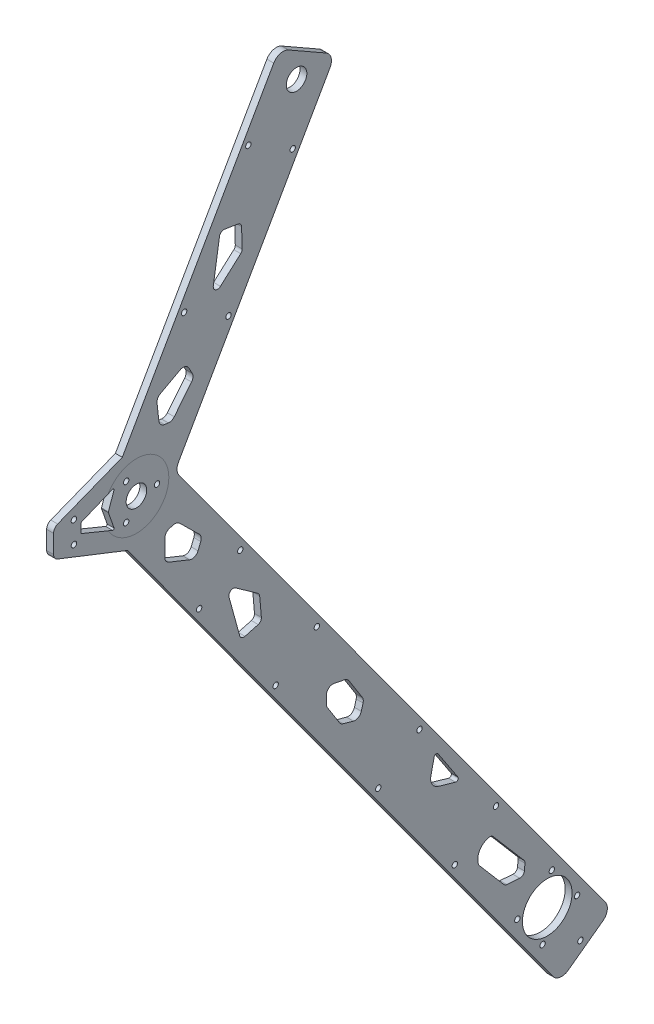
from build123d import *

# Parameters (mm, degrees)
SKETCH3_R                           = 4.765
SKETCH3_R_2                         = 11.5
SKETCH3_R_3                         = 1.25
BOSS_ROCKER_BASE_DEPTH              = 3.18
SKETCH4_R                           = 1.25
CUT_MOTOR_HOLES_SHAFT_SUPPORT_DEPTH = 3.18
SKETCH5_R                           = 1.25
CUT_SUPPORT_HOLES_DEPTH             = 3.18
CUT_LIGHTENING_HOLES_DEPTH          = 3.18


with BuildPart() as part:
    # Sketch3 → Boss-rocker base (new body)
    with BuildSketch(Plane.YZ):
        with BuildLine():
            Line((-19.740098585, 194.326279503), (-289.03382674, -2.652716496))
            ThreePointArc((-289.03382674, -2.652716496), (-291.022843538, -5.922039532), (-290.117530314, -9.640247287))
            Line((-290.117530314, -9.640247287), (-278.309875879, -25.782716018))
            ThreePointArc((-278.309875879, -25.782716018), (-275.040552842, -27.771732816), (-271.322345088, -26.866419592))
            Line((-271.322345088, -26.866419592), (-1.602441241, 170.424309102))
            ThreePointArc((-1.602441241, 170.424309102), (1.066332673, 171.380668673), (3.826130086, 170.732211983))
            Line((3.826130086, 170.732211983), (126.91354691, 100.548260636))
            ThreePointArc((126.91354691, 100.548260636), (130.710275653, 100.069186741), (133.733724692, 102.415122982))
            Line((133.733724692, 102.415122982), (143.640355564, 119.789203239))
            ThreePointArc((143.640355564, 119.789203239), (144.119429459, 123.585931982), (141.773493218, 126.609381021))
            Line((141.773493218, 126.609381021), (18.794188293, 196.731687397))
            Line((18.794188293, 196.731687397), (7.025536002, 226.658847865))
            ThreePointArc((7.025536002, 226.658847865), (5.922779586, 228.040238472), (4.233648495, 228.560957093))
            Line((4.233648495, 228.560957093), (-4.233648495, 228.560957093))
            ThreePointArc((-4.233648495, 228.560957093), (-5.922779586, 228.040238472), (-7.025536002, 226.658847865))
            Line((-7.025536002, 226.658847865), (-19.740098585, 194.326279503))
        make_face()
        with Locations((0, 190.180957093)):
            Circle(SKETCH3_R, mode=Mode.SUBTRACT)
        with Locations((-260, 0)):
            Circle(SKETCH3_R_2, mode=Mode.SUBTRACT)
        with Locations((130, 116.055478547)):
            Circle(SKETCH3_R, mode=Mode.SUBTRACT)
        with Locations((-5, 219.130957093)):
            Circle(SKETCH3_R_3, mode=Mode.SUBTRACT)
        with Locations((5, 219.130957093)):
            Circle(SKETCH3_R_3, mode=Mode.SUBTRACT)
    extrude(amount=BOSS_ROCKER_BASE_DEPTH)

    # Sketch4 → Cut-motor holes + shaft support (cut)
    with BuildSketch(Plane.YZ):
        with Locations((0, 180.656752709)):
            Circle(SKETCH4_R)
        with Locations((-8.24, 194.928851363)):
            Circle(SKETCH4_R)
        with Locations((8.24, 194.928851363)):
            Circle(SKETCH4_R)
        with Locations((-273.836126141, 2.145136678)):
            Circle(SKETCH4_R)
        with Locations((-257.855082097, 13.834714568)):
            Circle(SKETCH4_R)
        with Locations((-262.144917759, -13.834714591)):
            Circle(SKETCH4_R)
        with Locations((-246.163873715, -2.1451367)):
            Circle(SKETCH4_R)
    extrude(amount=CUT_MOTOR_HOLES_SHAFT_SUPPORT_DEPTH, mode=Mode.SUBTRACT)

    # Sketch5 → Cut-support holes (cut)
    with BuildSketch(Plane.YZ):
        with Locations((-173.097097557, 78.211050768)):
            Circle(SKETCH5_R)
        with Locations((-159.140450015, 59.130652728)):
            Circle(SKETCH5_R)
        with Locations((-94.167013372, 106.656461829)):
            Circle(SKETCH5_R)
        with Locations((-108.123660914, 125.73685987)):
            Circle(SKETCH5_R)
        with Locations((-221.524503751, 42.788087462)):
            Circle(SKETCH5_R)
        with Locations((-207.567856209, 23.707689422)):
            Circle(SKETCH5_R)
        with Locations((-45.739607178, 142.079425135)):
            Circle(SKETCH5_R)
        with Locations((-59.69625472, 161.159823175)):
            Circle(SKETCH5_R)
        with Locations((103.007538851, 117.839995969)):
            Circle(SKETCH5_R)
        with Locations((114.717176541, 138.376158833)):
            Circle(SKETCH5_R)
        with Locations((62.594935771, 168.096051448)):
            Circle(SKETCH5_R)
        with Locations((50.885298081, 147.559888585)):
            Circle(SKETCH5_R)
        with Locations((-280.985209351, -15.349950766)):
            Circle(SKETCH5_R)
    extrude(amount=CUT_SUPPORT_HOLES_DEPTH, mode=Mode.SUBTRACT)

    # Sketch6 → Cut-lightening holes (cut)
    with BuildSketch(Plane.YZ):
        with BuildLine():
            Line((-79.983471427, 142.368791683), (-61.979782767, 147.316428458))
            ThreePointArc((-61.979782767, 147.316428458), (-59.811067724, 146.534457497), (-59.819745898, 144.229088067))
            Line((-59.819745898, 144.229088067), (-67.122963599, 133.95613022))
            ThreePointArc((-67.122963599, 133.95613022), (-67.760393878, 133.378682327), (-68.581402, 133.122344477))
            Line((-68.581402, 133.122344477), (-77.604831251, 132.34516891))
            ThreePointArc((-77.604831251, 132.34516891), (-78.919471752, 132.69660063), (-79.704956379, 133.807815192))
            Line((-79.704956379, 133.807815192), (-81.381998087, 139.910311831))
            ThreePointArc((-81.381998087, 139.910311831), (-81.191902606, 141.429196112), (-79.983471427, 142.368791683))
        make_face()
        with BuildLine():
            Line((-23.474916203, 177.031971532), (-31.234891161, 177.031971532))
            ThreePointArc((-31.234891161, 177.031971532), (-32.91387852, 176.518133523), (-34.017714198, 175.152639164))
            Line((-34.017714198, 175.152639164), (-37.880265406, 165.561216901))
            ThreePointArc((-37.880265406, 165.561216901), (-37.857627092, 163.26522791), (-36.218110002, 161.657726231))
            Line((-36.218110002, 161.657726231), (-33.122502329, 160.411097438))
            ThreePointArc((-33.122502329, 160.411097438), (-31.392547815, 160.256443753), (-29.866816812, 161.086386695))
            Line((-29.866816812, 161.086386695), (-20.893300564, 170.176925526))
            ThreePointArc((-20.893300564, 170.176925526), (-20.132536099, 171.500594144), (-20.121734598, 173.027271748))
            Line((-20.121734598, 173.027271748), (-20.568332353, 174.774783973))
            ThreePointArc((-20.568332353, 174.774783973), (-21.634866927, 176.401405781), (-23.474916203, 177.031971532))
        make_face()
        with BuildLine():
            Line((-123.842513182, 102.258163939), (-127.383477271, 102.258163939))
            ThreePointArc((-127.383477271, 102.258163939), (-128.217930269, 102.139776022), (-128.986523832, 101.793956069))
            Line((-128.986523832, 101.793956069), (-137.87452461, 96.175246667))
            ThreePointArc((-137.87452461, 96.175246667), (-138.681600876, 95.425877769), (-139.163866001, 94.435753436))
            Line((-139.163866001, 94.435753436), (-140.452603638, 89.754685534))
            ThreePointArc((-140.452603638, 89.754685534), (-140.168511172, 87.476227852), (-138.356514585, 86.065998684))
            Line((-138.356514585, 86.065998684), (-135.427175254, 85.259526758))
            ThreePointArc((-135.427175254, 85.259526758), (-134.189854142, 85.184508534), (-133.027829794, 85.61612258))
            Line((-133.027829794, 85.61612258), (-123.19292846, 91.833432183))
            ThreePointArc((-123.19292846, 91.833432183), (-122.319685125, 92.675710701), (-121.851449189, 93.794970338))
            Line((-121.851449189, 93.794970338), (-120.89798735, 98.683909964))
            ThreePointArc((-120.89798735, 98.683909964), (-121.527047578, 101.165680397), (-123.842513182, 102.258163939))
        make_face()
        with BuildLine():
            Line((-173.179518759, 50.529751316), (-187.062617136, 41.348992712))
            ThreePointArc((-187.062617136, 41.348992712), (-188.206182034, 41.377149334), (-188.575130176, 42.459928509))
            Line((-188.575130176, 42.459928509), (-186.300929891, 50.354284082))
            ThreePointArc((-186.300929891, 50.354284082), (-184.055505641, 53.265590831), (-180.426317386, 53.854343461))
            Line((-180.426317386, 53.854343461), (-173.517109299, 52.340698989))
            ThreePointArc((-173.517109299, 52.340698989), (-172.74804587, 51.547125046), (-173.179518759, 50.529751316))
        make_face()
        with BuildLine():
            Line((-227.536912906, 31.443521835), (-240.812092581, 20.074883922))
            ThreePointArc((-240.812092581, 20.074883922), (-241.294394217, 19.461411125), (-241.505216951, 18.71006732))
            Line((-241.505216951, 18.71006732), (-241.969357294, 12.71062362))
            ThreePointArc((-241.969357294, 12.71062362), (-241.494399162, 11.255439603), (-240.129582559, 10.562315233))
            Line((-240.129582559, 10.562315233), (-237.156438151, 10.332301196))
            ThreePointArc((-237.156438151, 10.332301196), (-236.381608619, 10.425053213), (-235.701254134, 10.807259329))
            Line((-235.701254134, 10.807259329), (-219.133655325, 24.995468947))
            ThreePointArc((-219.133655325, 24.995468947), (-218.552793599, 25.837124808), (-218.463915883, 26.855891554))
            ThreePointArc((-218.463915883, 26.855891554), (-221.531743706, 31.287956059), (-226.896432107, 31.812247659))
            ThreePointArc((-226.896432107, 31.812247659), (-227.233851743, 31.657725269), (-227.536912906, 31.443521835))
        make_face()
        with BuildLine():
            Line((85.568117513, 143.181930885), (86.544369033, 149.434919538))
            ThreePointArc((86.544369033, 149.434919538), (86.183746182, 150.922567652), (84.87682125, 151.719494858))
            Line((84.87682125, 151.719494858), (66.429148509, 154.599648582))
            ThreePointArc((66.429148509, 154.599648582), (64.362763101, 153.577467158), (64.632063287, 151.28786437))
            Line((64.632063287, 151.28786437), (73.050048081, 141.906596667))
            ThreePointArc((73.050048081, 141.906596667), (73.74868466, 141.404929088), (74.593412473, 141.243070035))
            Line((74.593412473, 141.243070035), (83.646848899, 141.491195361))
            ThreePointArc((83.646848899, 141.491195361), (84.913320183, 141.989025039), (85.568117513, 143.181930885))
        make_face()
        with BuildLine():
            Line((21.93232317, 175.41253387), (22.178458249, 177.199337176))
            ThreePointArc((22.178458249, 177.199337176), (23.054223795, 178.936124213), (24.811171332, 179.770707856))
            Line((24.811171332, 179.770707856), (32.521378103, 180.648160365))
            ThreePointArc((32.521378103, 180.648160365), (34.247699157, 180.327467884), (35.498857547, 179.095546323))
            Line((35.498857547, 179.095546323), (40.421178328, 170.0023928))
            ThreePointArc((40.421178328, 170.0023928), (40.658302188, 167.718569205), (39.211066927, 165.935990164))
            Line((39.211066927, 165.935990164), (36.27627425, 164.347323378))
            ThreePointArc((36.27627425, 164.347323378), (34.574902041, 163.998048434), (32.965111147, 164.650147857))
            Line((32.965111147, 164.650147857), (23.021241192, 172.667712351))
            ThreePointArc((23.021241192, 172.667712351), (22.115683157, 173.896868902), (21.93232317, 175.41253387))
        make_face()
        with BuildLine():
            Line((1.921390016, 215.785081873), (-1.921390016, 215.785081873))
            ThreePointArc((-1.921390016, 215.785081873), (-2.199739759, 215.700438853), (-2.38384805, 215.475167556))
            Line((-2.38384805, 215.475167556), (-8.248888496, 201.206154542))
            ThreePointArc((-8.248888496, 201.206154542), (-8.149028051, 200.671797182), (-7.620562901, 200.544382574))
            Line((-7.620562901, 200.544382574), (-0.165867561, 203.165811621))
            ThreePointArc((-0.165867561, 203.165811621), (0, 203.194125335), (0.165867561, 203.165811621))
            Line((0.165867561, 203.165811621), (7.620562901, 200.544382574))
            ThreePointArc((7.620562901, 200.544382574), (8.149028051, 200.671797182), (8.248888496, 201.206154542))
            Line((8.248888496, 201.206154542), (2.38384805, 215.475167556))
            ThreePointArc((2.38384805, 215.475167556), (2.199739759, 215.700438853), (1.921390016, 215.785081873))
        make_face()
    extrude(amount=CUT_LIGHTENING_HOLES_DEPTH, mode=Mode.SUBTRACT)


solid = part.part
